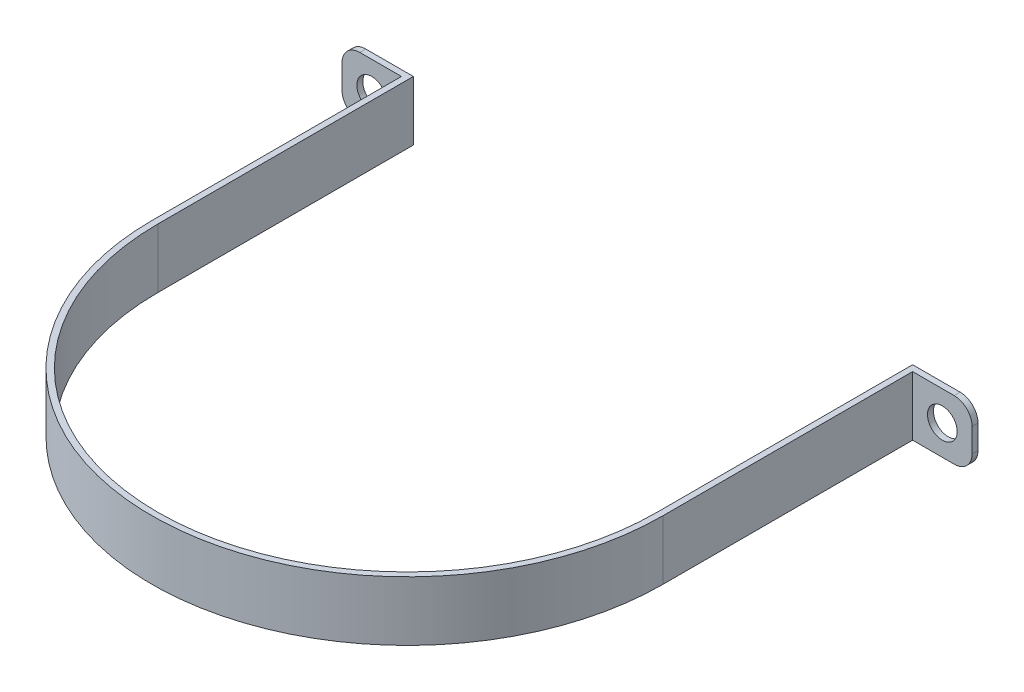
from build123d import *

# Parameters (mm, degrees)
DODANIE_WYCI_GNI_CIE1_DEPTH = 10
SZKIC3_W                    = 10
SZKIC3_H                    = 10
DODANIE_WYCI_GNI_CIE2_DEPTH = 1
ZAOKR_GLENIE1_R             = 3
ZAOKR_GLENIE2_R             = 3
SZKIC5_R                    = 2.5
WYTNIJ_WYCI_GNI_CIE1_DEPTH  = 1
ZAOKR_GLENIE1_OF_LUSTRO1_R  = 3
ZAOKR_GLENIE2_OF_LUSTRO1_R  = 3


with BuildPart() as part:
    # Szkic2 → Dodanie-wyciągnięcie1 (new body)
    with BuildSketch(Plane(origin=(0, 0, 0), x_dir=(1, 0, 0), z_dir=(0, 1, 0))):
        with BuildLine():
            Line((-43, 43), (-42, 43))
            Line((-42, 43), (-42, 0))
            ThreePointArc((-42, 0), (0, -42), (42, 0))
            Line((42, 0), (42, 43))
            Line((42, 43), (43, 43))
            Line((43, 43), (43, 0))
            ThreePointArc((43, 0), (0, -43), (-43, 0))
            Line((-43, 0), (-43, 43))
        make_face()
    extrude(amount=DODANIE_WYCI_GNI_CIE1_DEPTH)

    # Szkic3 → Dodanie-wyciągnięcie2 (add)
    with BuildSketch(Plane(origin=(0, 0, -43), x_dir=(-1, 0, 0), z_dir=(0, 0, -1))):
        with Locations((-48, 5)):
            Rectangle(SZKIC3_W, SZKIC3_H)
    dodanie_wyci_gni_cie2 = extrude(amount=-DODANIE_WYCI_GNI_CIE2_DEPTH)

    # Zaokrąglenie1
    zaokr_glenie1_edges = [part.edges().sort_by_distance(p)[0] for p in [
        (53, 10, -42.5),
    ]]
    fillet(zaokr_glenie1_edges, radius=ZAOKR_GLENIE1_R)

    # Zaokrąglenie2
    zaokr_glenie2_edges = [part.edges().sort_by_distance(p)[0] for p in [
        (53, 0, -42.5),
    ]]
    fillet(zaokr_glenie2_edges, radius=ZAOKR_GLENIE2_R)

    # Szkic5 → Wytnij-wyciągnięcie1 (cut)
    with BuildSketch(Plane(origin=(0, 0, -43), x_dir=(-1, 0, 0), z_dir=(0, 0, -1))):
        with Locations((-48, 5)):
            Circle(SZKIC5_R)
    wytnij_wyci_gni_cie1 = extrude(amount=-WYTNIJ_WYCI_GNI_CIE1_DEPTH, mode=Mode.SUBTRACT)

    # Lustro1: Dodanie-wyciągnięcie2, Wytnij-wyciągnięcie1 across plane
    add(dodanie_wyci_gni_cie2.mirror(Plane(origin=(0, 0, 0), x_dir=(0, 0, 1), z_dir=(1, 0, 0))))
    add(wytnij_wyci_gni_cie1.mirror(Plane(origin=(0, 0, 0), x_dir=(0, 0, 1), z_dir=(1, 0, 0))), mode=Mode.SUBTRACT)

    # Zaokrąglenie1 of Lustro1
    zaokr_glenie1_of_lustro1_edges = [part.edges().sort_by_distance(p)[0] for p in [
        (-53, 10, -42.5),
    ]]
    fillet(zaokr_glenie1_of_lustro1_edges, radius=ZAOKR_GLENIE1_OF_LUSTRO1_R)

    # Zaokrąglenie2 of Lustro1
    zaokr_glenie2_of_lustro1_edges = [part.edges().sort_by_distance(p)[0] for p in [
        (-53, 0, -42.5),
    ]]
    fillet(zaokr_glenie2_of_lustro1_edges, radius=ZAOKR_GLENIE2_OF_LUSTRO1_R)


solid = part.part
